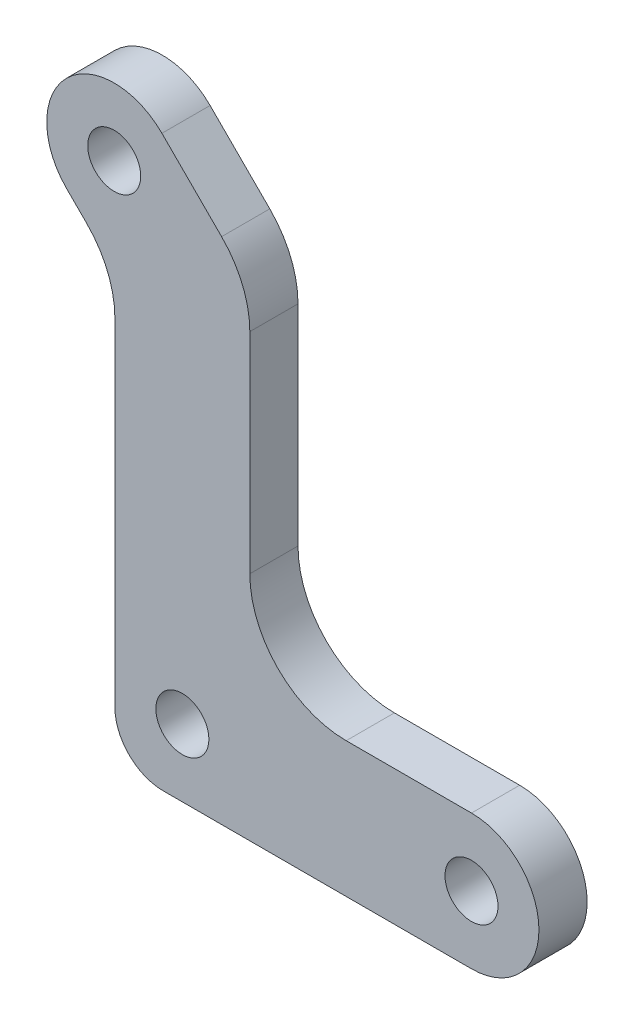
from build123d import *

# Parameters (mm, degrees)
SKETCH_1_R      = 2.75
EXTRUDE_1_DEPTH = 5


with BuildPart() as part:
    # 草圖1 → 填料-伸長1 (new body)
    with BuildSketch(Plane.XY):
        with BuildLine():
            Line((17, 7), (30, 7))
            ThreePointArc((30, 7), (37, 0), (30, -7))
            Line((30, -7), (-2, -7))
            ThreePointArc((-2, -7), (-5.535533906, -5.535533906), (-7, -2))
            Line((-7, -2), (-7, 32.95836944))
            ThreePointArc((-7, 32.95836944), (-7.761204675, 36.785203763), (-9.928932188, 40.029437252))
            Line((-9.928932188, 40.029437252), (-12.02081528, 42.121320344))
            ThreePointArc((-12.02081528, 42.121320344), (-12.02081528, 52.02081528), (-2.121320344, 52.02081528))
            Line((-2.121320344, 52.02081528), (4.071067812, 45.828427125))
            ThreePointArc((4.071067812, 45.828427125), (6.238795325, 42.584193637), (7, 38.757359313))
            Line((7, 38.757359313), (7, 17))
            ThreePointArc((7, 17), (9.928932188, 9.928932188), (17, 7))
        make_face()
        Circle(SKETCH_1_R, mode=Mode.SUBTRACT)
        with Locations((30, 0)):
            Circle(SKETCH_1_R, mode=Mode.SUBTRACT)
        with Locations((-7.071067812, 47.071067812)):
            Circle(SKETCH_1_R, mode=Mode.SUBTRACT)
    extrude(amount=EXTRUDE_1_DEPTH)


solid = part.part
